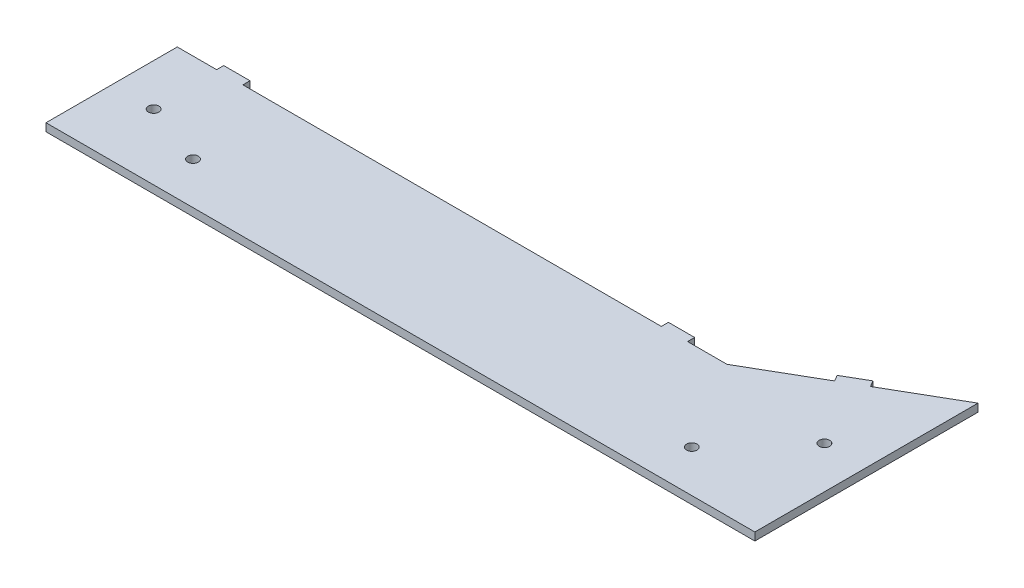
from build123d import *

# Parameters (mm, degrees)
BOSS_EXTRUDE1_DEPTH = 3
CUT_EXTRUDE1_REACH  = 5
SKETCH2_R           = 2
CUT_EXTRUDE2_REACH  = 5
SKETCH3_R           = 2
SKETCH4_W           = 10
SKETCH4_H           = 3
BOSS_EXTRUDE3_DEPTH = 2.7
SKETCH5_W           = 10
SKETCH5_H           = 3
BOSS_EXTRUDE4_DEPTH = 2.7


with BuildPart() as part:
    # Sketch1 → Boss-Extrude1 (new body)
    with BuildSketch(Plane(origin=(0, 0, 0), x_dir=(1, 0, 0), z_dir=(0, 1, 0))):
        Polygon((101.124303582, 11.213732055), (101.124303582, 66.273277114), (40.502525317, 31.273277114), (-168.875696418, 31.273277114), (-168.875696418, -18.726722886), (101.124303582, -18.726722886), align=None)
    extrude(amount=BOSS_EXTRUDE1_DEPTH)

    # Sketch2 → Cut-Extrude1 (cut, up to next)
    with BuildSketch(Plane(origin=(0, 3, 0), x_dir=(1, 0, 0), z_dir=(0, 1, 0)), mode=Mode.PRIVATE) as cut_extrude1_sk1:
        with Locations(Location((-152.875696418, 6.273277114, 0), (0, 0, 270))):  # turned: the seam where the file's is
            Circle(SKETCH2_R)
    cut_extrude1_tool1 = extrude(cut_extrude1_sk1.sketch, amount=-CUT_EXTRUDE1_REACH, mode=Mode.PRIVATE) & part.part
    add(cut_extrude1_tool1.solids().sort_by_distance((-152.875696, 3, -6.273277))[0], mode=Mode.SUBTRACT)
    # Sketch2 → Cut-Extrude1 (cut, up to next)
    with BuildSketch(Plane(origin=(0, 3, 0), x_dir=(1, 0, 0), z_dir=(0, 1, 0)), mode=Mode.PRIVATE) as cut_extrude1_sk2:
        with Locations(Location((85.124303582, 23.773277114, 0), (0, 0, 270))):  # turned: the seam where the file's is
            Circle(SKETCH2_R)
    cut_extrude1_tool2 = extrude(cut_extrude1_sk2.sketch, amount=-CUT_EXTRUDE1_REACH, mode=Mode.PRIVATE) & part.part
    add(cut_extrude1_tool2.solids().sort_by_distance((85.124304, 3, -23.773277))[0], mode=Mode.SUBTRACT)

    # Sketch3 → Cut-Extrude2 (cut, up to next)
    with BuildSketch(Plane(origin=(0, 3, 0), x_dir=(1, 0, 0), z_dir=(0, 1, 0)), mode=Mode.PRIVATE) as cut_extrude2_sk1:
        with Locations(Location((-128.875696418, -2.726722886, 0), (0, 0, 270))):  # turned: the seam where the file's is
            Circle(SKETCH3_R)
    cut_extrude2_tool1 = extrude(cut_extrude2_sk1.sketch, amount=-CUT_EXTRUDE2_REACH, mode=Mode.PRIVATE) & part.part
    add(cut_extrude2_tool1.solids().sort_by_distance((-128.875696, 3, 2.726723))[0], mode=Mode.SUBTRACT)
    # Sketch3 → Cut-Extrude2 (cut, up to next)
    with BuildSketch(Plane(origin=(0, 3, 0), x_dir=(1, 0, 0), z_dir=(0, 1, 0)), mode=Mode.PRIVATE) as cut_extrude2_sk2:
        with Locations(Location((61.124303582, -2.726722886, 0), (0, 0, 270))):  # turned: the seam where the file's is
            Circle(SKETCH3_R)
    cut_extrude2_tool2 = extrude(cut_extrude2_sk2.sketch, amount=-CUT_EXTRUDE2_REACH, mode=Mode.PRIVATE) & part.part
    add(cut_extrude2_tool2.solids().sort_by_distance((61.124304, 3, 2.726723))[0], mode=Mode.SUBTRACT)

    # Sketch4 → Boss-Extrude3 (add)
    with BuildSketch(Plane.XY.offset(-31.273277114)):
        with Locations((-148.875696418, 1.5)):
            Rectangle(SKETCH4_W, SKETCH4_H)
        with Locations((20.502525317, 1.5)):
            Rectangle(SKETCH4_W, SKETCH4_H)
    extrude(amount=-BOSS_EXTRUDE3_DEPTH)

    # Sketch5 → Boss-Extrude4 (add)
    with BuildSketch(Plane(origin=(-3.416094891, 0, -5.916849915), x_dir=(-0.866025404, 0, 0.5), z_dir=(-0.5, 0, -0.866025404))):
        with Locations((-85.712854399, 1.5)):
            Rectangle(SKETCH5_W, SKETCH5_H)
    extrude(amount=BOSS_EXTRUDE4_DEPTH)


solid = part.part
